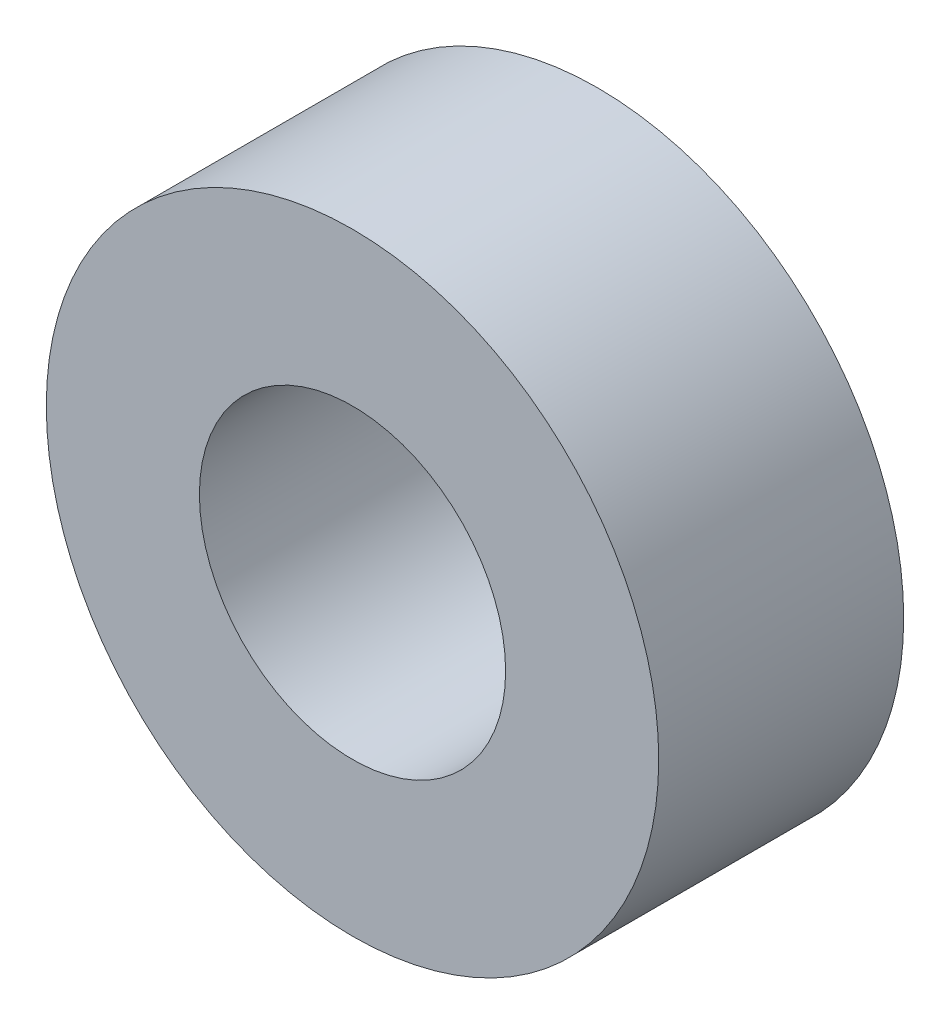
from build123d import *

# Parameters (mm, degrees)
SKETCH1_R                 = 5
BOSS_EXTRUDE1_DEPTH       = 4
F_5_0MM_DOWEL_HOLE1_D     = 5
F_5_0MM_DOWEL_HOLE1_DEPTH = 12.75
F_5_0MM_DOWEL_HOLE1_TIP   = 1.502151548


with BuildPart() as part:
    # Sketch1 → Boss-Extrude1 (new body)
    with BuildSketch(Plane.XY):
        Circle(SKETCH1_R)
    extrude(amount=BOSS_EXTRUDE1_DEPTH)

    # Ø5.0mm Dowel Hole1
    with Locations(Plane(origin=(0, 0, 0), x_dir=(-1, 0, 0), z_dir=(0, 0, -1))):
        with Locations((0, 0)):
            Hole(F_5_0MM_DOWEL_HOLE1_D / 2, depth=F_5_0MM_DOWEL_HOLE1_DEPTH)
            with Locations((0, 0, -(F_5_0MM_DOWEL_HOLE1_DEPTH + F_5_0MM_DOWEL_HOLE1_TIP / 2))):  # 118° drill point
                Cone(0, F_5_0MM_DOWEL_HOLE1_D / 2, F_5_0MM_DOWEL_HOLE1_TIP, mode=Mode.SUBTRACT)


solid = part.part
